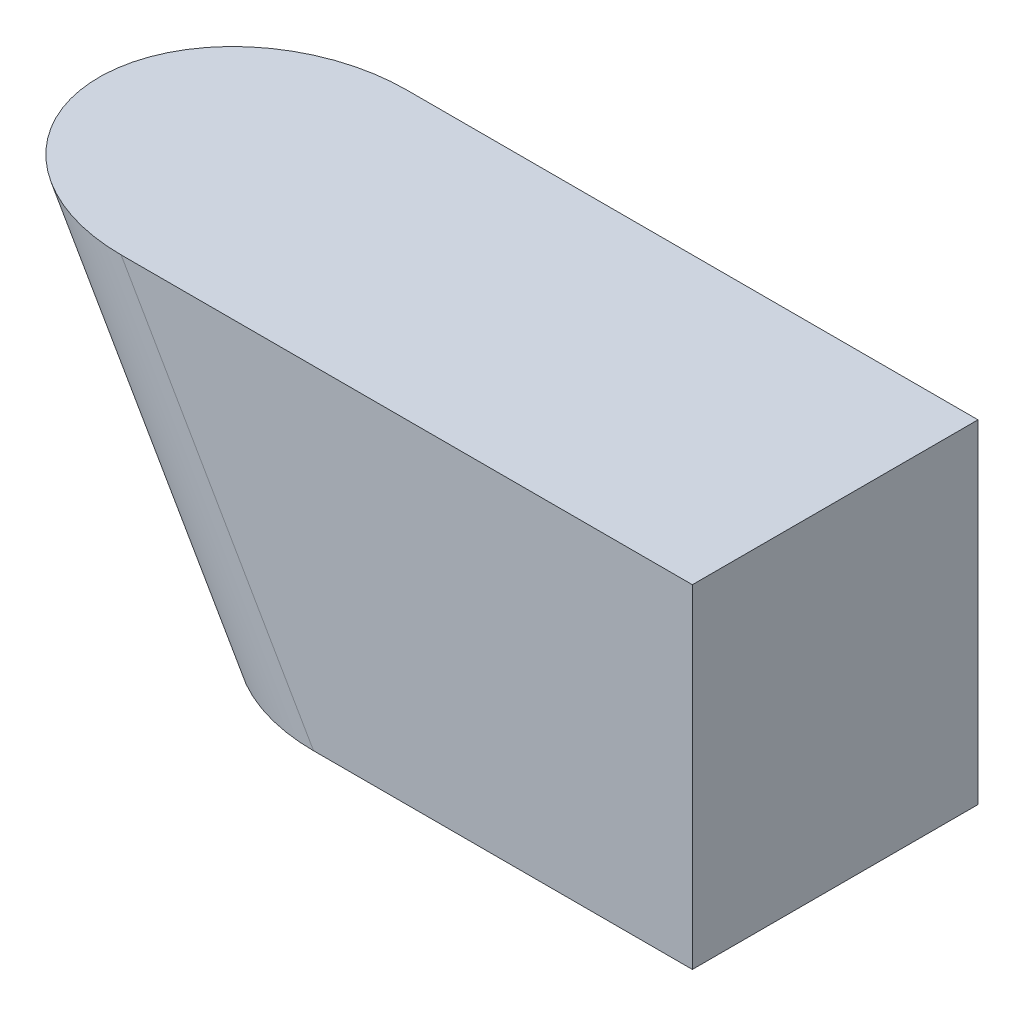
from build123d import *

# Parameters (mm, degrees)
AUFSATZ_LINEAR_AUSTRAGEN1_DEPTH             = 150
AUFSATZ_LINEAR_AUSTRAGEN2_REACH             = 712.634
AUFSATZ_LINEAR_AUSTRAGEN2_DIRECTION_2_REACH = 712.634


with BuildPart() as part:
    # Skizze1 → Aufsatz-Linear austragen1 (new, symmetric)
    with BuildSketch(Plane.XY):
        Polygon((0, 0), (-202.072594216, 350), (397.927405784, 350), (397.927405784, 0), align=None)
    extrude(amount=AUFSATZ_LINEAR_AUSTRAGEN1_DEPTH, both=True)

    # Aufsatz-Linear austragen2: up to this face of the body (flat: up to its plane)
    aufsatz_linear_austragen2_end = Plane(part.part.faces().sort_by_distance((198.963702892, 0, 0))[0])
    # Skizze3 → Aufsatz-Linear austragen2 (add, up to the picked face)
    with BuildSketch(Plane(origin=(-202.072594216, 350, 0), x_dir=(0, 0, -1), z_dir=(-0.4999999999999981, 0.8660254037844398, 0)), mode=Mode.PRIVATE) as aufsatz_linear_austragen2_sk1:
        with BuildLine():
            Line((150, 0), (-150, 0))
            ThreePointArc((-150, 0), (0, 150), (150, 0))
        make_face()
    aufsatz_linear_austragen2_tool1 = split(extrude(aufsatz_linear_austragen2_sk1.sketch, amount=-AUFSATZ_LINEAR_AUSTRAGEN2_REACH, mode=Mode.PRIVATE), bisect_by=aufsatz_linear_austragen2_end, keep=Keep.BOTH, mode=Mode.PRIVATE)
    add(aufsatz_linear_austragen2_tool1.solids().sort_by(Axis((-257.205484, 318.169011, 0), (0.4999999999999981, -0.8660254037844398, 0)))[0])

    # Aufsatz-Linear austragen2 direction 2: up to this face of the body (flat: up to its plane)
    aufsatz_linear_austragen2_direction_2_end = Plane(part.part.faces().sort_by_distance((97.927405784, 350, 0))[0])
    # Skizze3 → Aufsatz-Linear austragen2 direction 2 (add, up to the picked face)
    with BuildSketch(Plane(origin=(-202.072594216, 350, 0), x_dir=(0, 0, -1), z_dir=(-0.4999999999999981, 0.8660254037844398, 0)), mode=Mode.PRIVATE) as aufsatz_linear_austragen2_direction_2_sk1:
        with BuildLine():
            Line((150, 0), (-150, 0))
            ThreePointArc((-150, 0), (0, 150), (150, 0))
        make_face()
    aufsatz_linear_austragen2_direction_2_tool1 = split(extrude(aufsatz_linear_austragen2_direction_2_sk1.sketch, amount=AUFSATZ_LINEAR_AUSTRAGEN2_DIRECTION_2_REACH, mode=Mode.PRIVATE), bisect_by=aufsatz_linear_austragen2_direction_2_end, keep=Keep.BOTH, mode=Mode.PRIVATE)
    add(aufsatz_linear_austragen2_direction_2_tool1.solids().sort_by(Axis((-257.205484, 318.169011, 0), (-0.4999999999999981, 0.8660254037844398, 0)))[0])


solid = part.part
